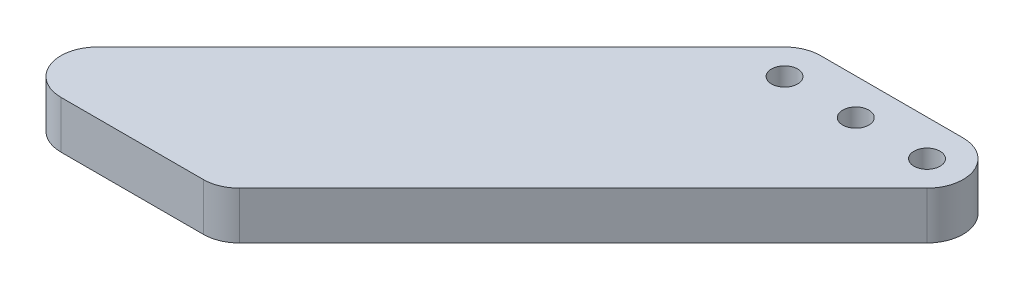
from build123d import *

# Parameters (mm, degrees)
BOSS_EXTRUDE1_DEPTH      = 5
FILLET1_R                = 7.6
M5_CLEARANCE_HOLE1_D     = 5.5
M5_CLEARANCE_HOLE1_DEPTH = 10


with BuildPart() as part:
    # Sketch1 → Boss-Extrude1 (new body, symmetric)
    with BuildSketch(Plane(origin=(0, 0, 0), x_dir=(1, 0, 0), z_dir=(0, 1, 0))):
        with BuildLine():
            Line((-15, 7.6), (15, 7.6))
            ThreePointArc((15, 7.6), (22.021484447, 2.908394086), (20.374011537, -5.374011537))
            Line((20.374011537, -5.374011537), (-54.251976926, -80))
            Line((-54.251976926, -80), (-105.748023074, -80))
            Line((-105.748023074, -80), (-20.374011537, 5.374011537))
            ThreePointArc((-20.374011537, 5.374011537), (-17.908394086, 7.021484447), (-15, 7.6))
        make_face()
    extrude(amount=BOSS_EXTRUDE1_DEPTH, both=True)

    # Fillet1
    fillet1_edges = [part.edges().sort_by_distance(p)[0] for p in [
        (-54.251976926, 0, 80),
        (-105.748023074, 0, 80),
    ]]
    fillet(fillet1_edges, radius=FILLET1_R)

    # M5 Clearance Hole1
    with Locations(Plane(origin=(0, 5, 0), x_dir=(1, 0, 0), z_dir=(0, 1, 0))):
        with Locations((-15, 0), (0, 0), (15, 0)):
            Hole(M5_CLEARANCE_HOLE1_D / 2, depth=M5_CLEARANCE_HOLE1_DEPTH)


solid = part.part
